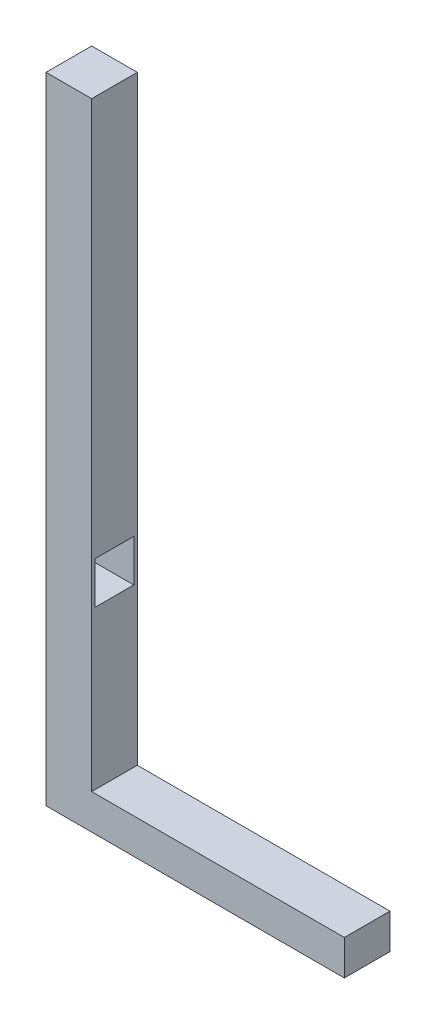
from build123d import *

# Parameters (mm, degrees)
ESQUISSE2_W             = 13
ESQUISSE2_H             = 171
BOSS_EXTRU_1_DEPTH      = 13
BOSS_EXTRU_2_DEPTH      = 13
ESQUISSE4_W             = 11
ESQUISSE4_H             = 12
ENL_V_MAT_EXTRU_2_DEPTH = 37


with BuildPart() as part:
    # Esquisse2 → Boss.-Extru.1 (new body)
    with BuildSketch(Plane.XY):
        with Locations((-64.835362299, 95.5)):
            Rectangle(ESQUISSE2_W, ESQUISSE2_H)
    extrude(amount=BOSS_EXTRU_1_DEPTH)

    # Esquisse2_3 → Boss.-Extru.2 (add)
    with BuildSketch(Plane.XY):
        Polygon((-58.335362299, 10), (-71.335362299, 10), (-71.335362299, 0), (13.664637701, 0), (13.664637701, 10), align=None)
    extrude(amount=BOSS_EXTRU_2_DEPTH)

    # Esquisse4 → Enlèv. mat.-Extru.2 (cut)
    with BuildSketch(Plane(origin=(-58.335362299, 0, 0), x_dir=(0, 0, -1), z_dir=(1, 0, 0))):
        with Locations((-6.5, 61)):
            Rectangle(ESQUISSE4_W, ESQUISSE4_H)
    extrude(amount=-ENL_V_MAT_EXTRU_2_DEPTH, mode=Mode.SUBTRACT)


solid = part.part
